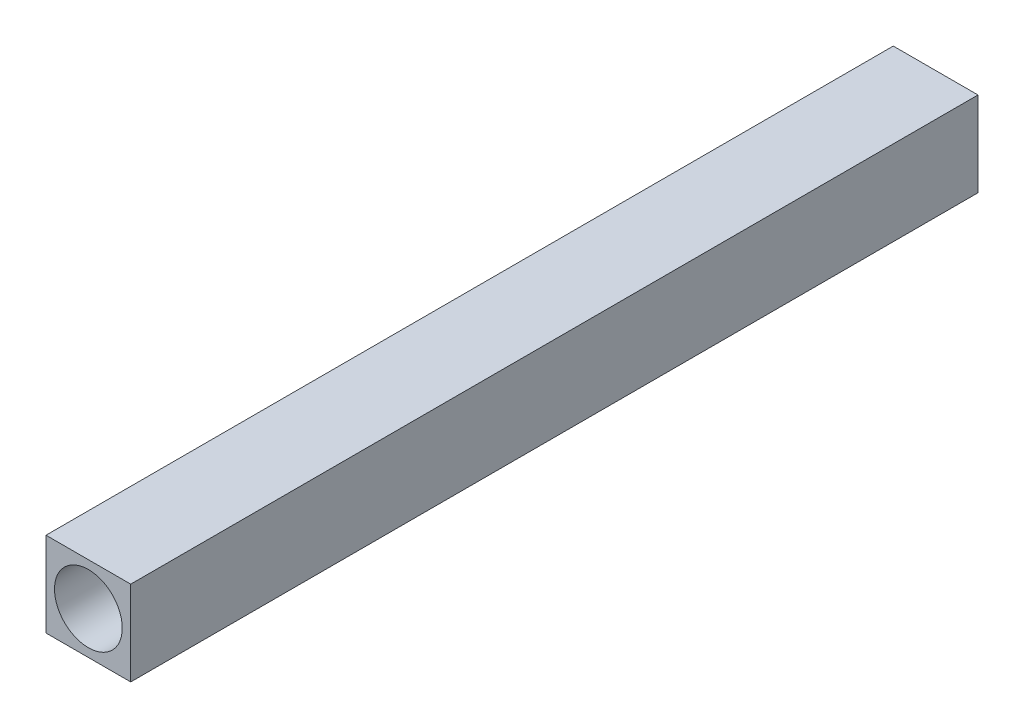
from build123d import *

# Parameters (mm, degrees)
SKETCH_1_W          = 10
SKETCH_1_H          = 10
EXTRUDE_1_DEPTH     = 100
SKETCH_2_R          = 4
CUT_EXTRUDE_1_DEPTH = 90


with BuildPart() as part:
    # 草图1 → 凸台-拉伸1 (new body)
    with BuildSketch(Plane.XY):
        Rectangle(SKETCH_1_W, SKETCH_1_H)
    extrude(amount=EXTRUDE_1_DEPTH)

    # 草图2 → 切除-拉伸1 (cut)
    with BuildSketch(Plane.XY.offset(100)):
        Circle(SKETCH_2_R)
    extrude(amount=-CUT_EXTRUDE_1_DEPTH, mode=Mode.SUBTRACT)


solid = part.part
